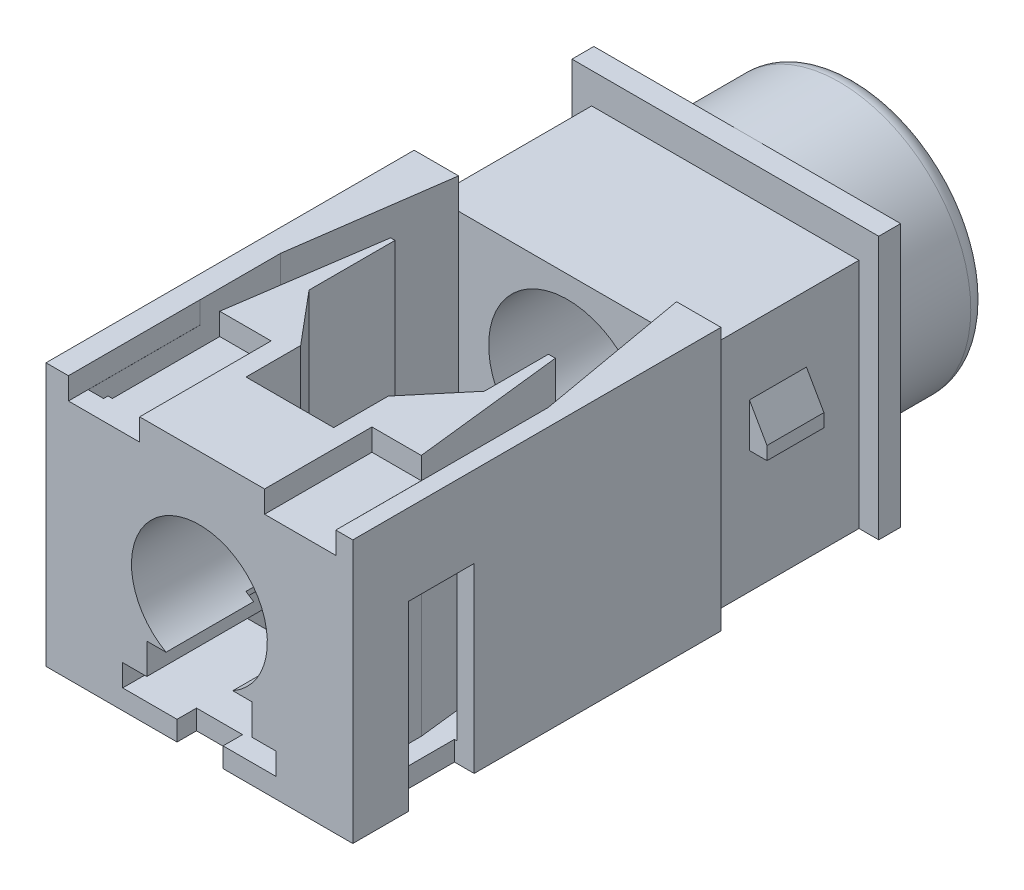
from build123d import *

# Parameters (mm, degrees)
SZKIC1_R                      = 3
SZKIC1_R_2                    = 1.8
DODANIE_WYCI_GNI_CIE1_DEPTH   = 2.5
SZKIC2_W                      = 7
SZKIC2_H                      = 6
SZKIC2_R                      = 1.8
DODANIE_WYCI_GNI_CIE2_DEPTH   = 0.5
ZAOKR_GLENIE1_R               = 0.4
SFAZOWANIE1_SIZE              = 0.4
SZKIC3_W                      = 6.1
SZKIC3_H                      = 5.3
SZKIC3_R                      = 1.8
DODANIE_WYCI_GNI_CIE3_DEPTH   = 3.6
DODANIE_WYCI_GNI_CIE4_START   = -0.1
DODANIE_WYCI_GNI_CIE4_DEPTH   = 1.3
SZKIC5_W                      = 7
SZKIC5_H                      = 6
SZKIC5_R                      = 1.55
DODANIE_WYCI_GNI_CIE5_DEPTH   = 8.4
SZKIC8_R                      = 0.475
DODANIE_WYCI_GNI_CIE6_DEPTH   = 0.8
DODANIE_WYCI_GNI_CIE6_2_DEPTH = 0.8
ZAOKR_GLENIE2_R               = 0.2
ZAOKR_GLENIE3_R               = 0.2
SZKIC9_W                      = 0.85
SZKIC9_H                      = 1.15
WYTNIJ_WYCI_GNI_CIE1_DEPTH    = 0.95
SZKIC10_W                     = 1.05
SZKIC10_H                     = 0.475
WYTNIJ_WYCI_GNI_CIE2_DEPTH    = 2
WYTNIJ_WYCI_GNI_CIE3_DEPTH    = 4.15
WYTNIJ_WYCI_GNI_CIE4_DEPTH    = 8.4
WYTNIJ_WYCI_GNI_CIE5_DEPTH    = 5.55
SZKIC14_W                     = 1.625
SZKIC14_H                     = 2.45
SZKIC14_H_2                   = 3
WYTNIJ_WYCI_GNI_CIE6_DEPTH    = 0.5


with BuildPart() as part:
    # Szkic1 → Dodanie-wyciągnięcie1 (new body)
    with BuildSketch(Plane.XY):
        Circle(SZKIC1_R)
        Circle(SZKIC1_R_2, mode=Mode.SUBTRACT)
    extrude(amount=DODANIE_WYCI_GNI_CIE1_DEPTH)

    # Szkic2 → Dodanie-wyciągnięcie2 (add)
    with BuildSketch(Plane.XY.offset(2.5)):
        Rectangle(SZKIC2_W, SZKIC2_H)
        Circle(SZKIC2_R, mode=Mode.SUBTRACT)
    extrude(amount=DODANIE_WYCI_GNI_CIE2_DEPTH)

    # Zaokrąglenie1
    zaokr_glenie1_edges = [part.edges().sort_by_distance(p)[0] for p in [
        (-3, 0, 0),
    ]]
    fillet(zaokr_glenie1_edges, radius=ZAOKR_GLENIE1_R)

    # Sfazowanie1
    sfazowanie1_edges = [part.edges().sort_by_distance(p)[0] for p in [
        (-1.8, 0, 0),
    ]]
    chamfer(sfazowanie1_edges, length=SFAZOWANIE1_SIZE)

    # Szkic3 → Dodanie-wyciągnięcie3 (add)
    with BuildSketch(Plane.XY.offset(3)):
        with Locations((0, -0.35)):
            Rectangle(SZKIC3_W, SZKIC3_H)
        Circle(SZKIC3_R, mode=Mode.SUBTRACT)
    extrude(amount=DODANIE_WYCI_GNI_CIE3_DEPTH)


with BuildPart() as body_2:
    # Szkic4 → Dodanie-wyciągnięcie4 (new body)
    with BuildSketch(Plane.XY.offset(4.3).offset(DODANIE_WYCI_GNI_CIE4_START)):
        Polygon((3.05, 0.790431876), (3.05, -0.209568124), (3.45, -0.209568124), (3.45, 0.090431876), align=None)
    extrude(amount=DODANIE_WYCI_GNI_CIE4_DEPTH)


with BuildPart() as body_3:
    # Lustro1: mirrored copy
    add(body_2.part.mirror(Plane(origin=(0, 0, 0), x_dir=(0, 0, 1), z_dir=(1, 0, 0))))


with BuildPart() as body_4:
    # Szkic5 → Dodanie-wyciągnięcie5 (new body)
    with BuildSketch(Plane.XY.offset(6.6)):
        Rectangle(SZKIC5_W, SZKIC5_H)
        Circle(SZKIC5_R, mode=Mode.SUBTRACT)
    extrude(amount=DODANIE_WYCI_GNI_CIE5_DEPTH)

    # Szkic9 → Wytnij-wyciągnięcie1 (cut)
    with BuildSketch(Plane.XZ.offset(3)):
        with Locations((1.325, 11.630923267)):
            Rectangle(SZKIC9_W, SZKIC9_H)
        with Locations((-1.325, 11.630923267)):
            Rectangle(SZKIC9_W, SZKIC9_H)
    extrude(amount=-WYTNIJ_WYCI_GNI_CIE1_DEPTH, mode=Mode.SUBTRACT)

    # Szkic10 → Wytnij-wyciągnięcie2 (cut)
    with BuildSketch(Plane.XZ.offset(3)):
        with Locations((0.015, 14.793423267)):
            Rectangle(SZKIC10_W, SZKIC10_H)
    extrude(amount=-WYTNIJ_WYCI_GNI_CIE2_DEPTH, mode=Mode.SUBTRACT)

    # Szkic11 → Wytnij-wyciągnięcie3 (cut)
    with BuildSketch(Plane.XZ.offset(3)):
        Polygon((3.05, 13.530923267), (2.7, 13.530923267), (2.7, 14.580923267), (3.05, 14.580923267), (3.05, 13.730923267), (3.5, 13.730923267), (3.5, 12.230923267), (3.05, 12.230923267), align=None)
        Polygon((-3.05, 13.530923267), (-3.05, 12.230923267), (-3.5, 12.230923267), (-3.5, 13.730923267), (-3.05, 13.730923267), (-3.05, 14.580923267), (-2.7, 14.580923267), (-2.7, 13.530923267), align=None)
    extrude(amount=-WYTNIJ_WYCI_GNI_CIE3_DEPTH, mode=Mode.SUBTRACT)

    # Szkic12 → Wytnij-wyciągnięcie4 (cut)
    with BuildSketch(Plane.XY.offset(15)):
        with BuildLine():
            Line((1.75, -2.05), (1.75, -2.55))
            Line((1.75, -2.55), (0.54, -2.55))
            Line((0.54, -2.55), (-0.51, -2.55))
            Line((-0.51, -2.55), (-1.75, -2.55))
            Line((-1.75, -2.55), (-1.75, -2.05))
            Line((-1.75, -2.05), (-1.2, -2.05))
            Line((-1.2, -2.05), (-1.2, -1.35))
            Line((-1.2, -1.35), (-0.761577311, -1.35))
            ThreePointArc((-0.761577311, -1.35), (0, 1.55), (0.761577311, -1.35))
            Line((0.761577311, -1.35), (1.2, -1.35))
            Line((1.2, -1.35), (1.2, -2.05))
            Line((1.2, -2.05), (1.75, -2.05))
        make_face()
    extrude(amount=-WYTNIJ_WYCI_GNI_CIE4_DEPTH, mode=Mode.SUBTRACT)

    # Szkic13 → Wytnij-wyciągnięcie5 (cut)
    with BuildSketch(Plane(origin=(0, 3, 0), x_dir=(1, 0, 0), z_dir=(0, 1, 0))):
        Polygon((-2.486342085, -6.6), (-2.986342085, -10.157684861), (-2.986342085, -14.55), (-2.636342085, -14.55), (-2.636342085, -14.45), (-2.536342085, -14.45), (-2.536342085, -12), (-2.036342085, -8.6), (-1.936342085, -8.6), (-1.936342085, -10.561649281), (-0.936342085, -11.753402874), (-0.936342085, -13), (1.063657915, -13), (1.063657915, -11.753402874), (2.063657915, -10.561649281), (2.063657915, -9.1), (2.220476097, -9.1), (2.612521551, -12.55), (2.612521551, -14.45), (2.763657915, -14.45), (2.763657915, -14.55), (3.113657915, -14.55), (3.113657915, -10.157684861), (2.486342085, -6.6), align=None)
    extrude(amount=-WYTNIJ_WYCI_GNI_CIE5_DEPTH, mode=Mode.SUBTRACT)

    # Szkic14 → Wytnij-wyciągnięcie6 (cut)
    with BuildSketch(Plane(origin=(0, 3, 0), x_dir=(1, 0, 0), z_dir=(0, 1, 0))):
        with Locations((2.299282609, -13.775)):
            Rectangle(SZKIC14_W, SZKIC14_H)
        with Locations((-2.175717391, -13.5)):
            Rectangle(SZKIC14_W, SZKIC14_H_2)
    extrude(amount=-WYTNIJ_WYCI_GNI_CIE6_DEPTH, mode=Mode.SUBTRACT)


with BuildPart() as body_5:
    # Szkic8 → Dodanie-wyciągnięcie6 (new body)
    with BuildSketch(Plane.XZ.offset(3)):
        with Locations((0, 11.530923267)):
            Circle(SZKIC8_R)
    extrude(amount=DODANIE_WYCI_GNI_CIE6_DEPTH)

    # Zaokrąglenie3
    zaokr_glenie3_edges = [body_5.edges().sort_by_distance(p)[0] for p in [
        (-0.475, -3.8, 11.530923267),
    ]]
    fillet(zaokr_glenie3_edges, radius=ZAOKR_GLENIE3_R)


with BuildPart() as body_6:
    # Szkic8 → Dodanie-wyci_gni_cie6 2 (new body)
    with BuildSketch(Plane.XZ.offset(3)):
        with Locations((0, 4.530923267)):
            Circle(SZKIC8_R)
    extrude(amount=DODANIE_WYCI_GNI_CIE6_2_DEPTH)

    # Zaokrąglenie2
    zaokr_glenie2_edges = [body_6.edges().sort_by_distance(p)[0] for p in [
        (-0.475, -3.8, 4.530923267),
    ]]
    fillet(zaokr_glenie2_edges, radius=ZAOKR_GLENIE2_R)


solid = Compound([part.part, body_2.part, body_3.part, body_4.part, body_5.part, body_6.part])
